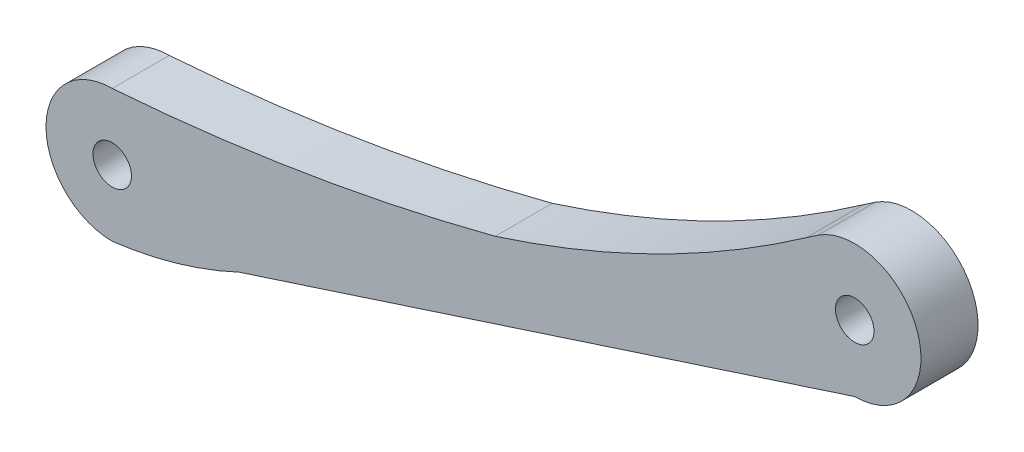
from build123d import *

# Parameters (mm, degrees)
SKETCH1_R           = 2.023987864
SKETCH1_R_2         = 2.023043511
BOSS_EXTRUDE1_DEPTH = 6


with BuildPart() as part:
    # Sketch1 → Boss-Extrude1 (new body)
    with BuildSketch(Plane.XY):
        with BuildLine():
            ThreePointArc((40.235925581, 13.621604134), (57.203735223, 20.491828906), (72.938383073, 29.847437358))
            Line((72.938383073, 29.847437358), (74.156447949, 30.67709719))
            ThreePointArc((74.156447949, 30.67709719), (84.681220688, 26.906078771), (78.020019153, 17.927224989))
            Line((78.020019153, 17.927224989), (13.323500668, -3.100956986))
            ThreePointArc((13.323500668, -3.100956986), (6.814395622, -5.556227345), (0, -6.956517793))
            ThreePointArc((0, -6.956517793), (-6.956517793, 0), (0, 6.956517793))
            ThreePointArc((0, 6.956517793), (20.269294729, 9.375497313), (40.235925581, 13.621604134))
        make_face()
        with Locations((78.020019153, 24.887546661)):
            Circle(SKETCH1_R, mode=Mode.SUBTRACT)
        Circle(SKETCH1_R_2, mode=Mode.SUBTRACT)
    extrude(amount=BOSS_EXTRUDE1_DEPTH)


solid = part.part
